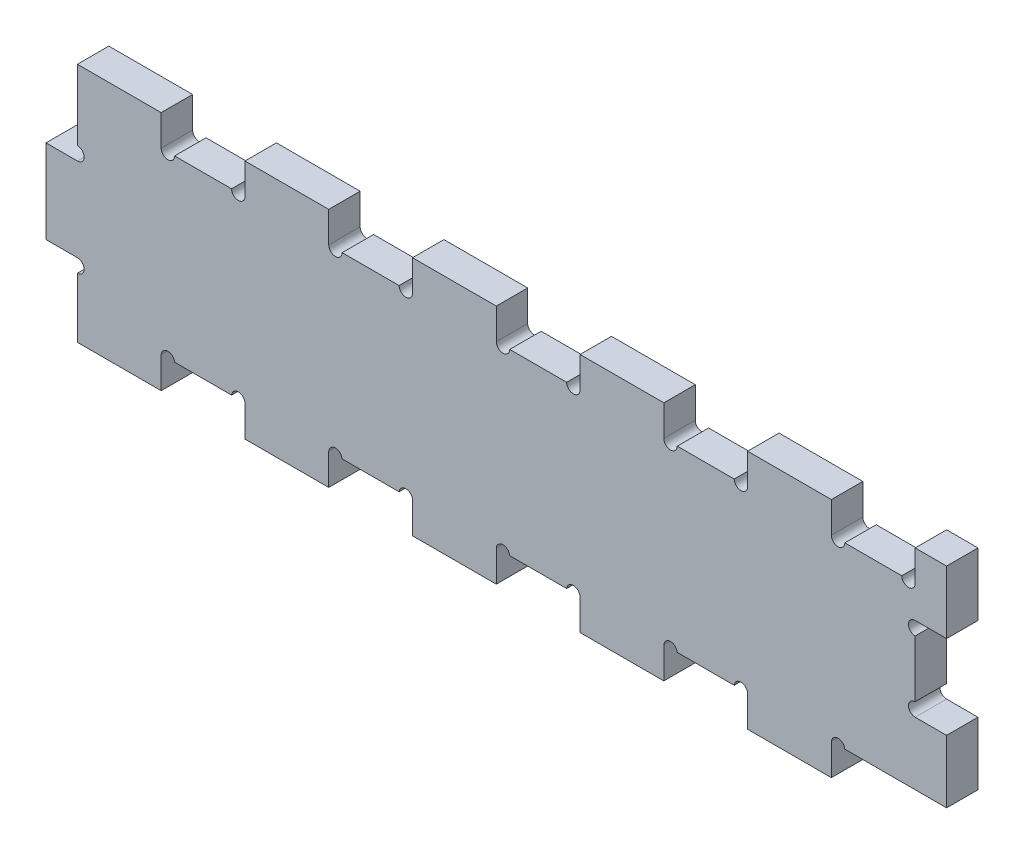
from build123d import *

# Parameters (mm, degrees)
SALIENTE_EXTRUIR2_DEPTH = 10
SALIENTE_EXTRUIR3_DEPTH = 5
CROQUIS4_W              = 15
CROQUIS4_H              = 40
CORTAR_EXTRUIR1_DEPTH   = 15
CROQUIS5_W              = 15
CROQUIS5_H              = 40
SALIENTE_EXTRUIR4_DEPTH = 15
SALIENTE_EXTRUIR5_DEPTH = 15
CROQUIS7_R              = 3.2
CORTAR_EXTRUIR2_DEPTH   = 15
CROQUIS8_W              = 15
CROQUIS8_H              = 30
SALIENTE_EXTRUIR6_DEPTH = 15
CROQUIS9_W              = 15
CROQUIS9_H              = 40
CORTAR_EXTRUIR3_DEPTH   = 15
SALIENTE_EXTRUIR8_DEPTH = 15
CROQUIS12_R             = 3.2
CORTAR_EXTRUIR4_DEPTH   = 15


with BuildPart() as part:
    # Croquis1 → Saliente-Extruir2 (new body)
    with BuildSketch(Plane.XY):
        with BuildLine():
            Line((-200, -42.5), (-200, -57.5))
            Line((-200, -57.5), (-160, -57.5))
            Line((-160, -57.5), (-160, -49.312229152))
            Line((-160, -49.312229152), (-160, -42.790697674))
            Line((-160, -42.790697674), (-160, -42.5))
            Line((-160, -42.5), (-159.986768718, -42.5))
            ThreePointArc((-159.986768718, -42.5), (-156.8, -39.590697674), (-153.613231282, -42.5))
            Line((-153.613231282, -42.5), (-126.386768718, -42.5))
            ThreePointArc((-126.386768718, -42.5), (-123.2, -39.590697674), (-120.013231282, -42.5))
            Line((-120.013231282, -42.5), (-120, -42.5))
            Line((-120, -42.5), (-120, -42.790697674))
            Line((-120, -42.790697674), (-120, -57.5))
            Line((-120, -57.5), (-80, -57.5))
            Line((-80, -57.5), (-80, -42.790697674))
            Line((-80, -42.790697674), (-80, -42.5))
            Line((-80, -42.5), (-79.986768718, -42.5))
            ThreePointArc((-79.986768718, -42.5), (-76.8, -39.590697674), (-73.613231282, -42.5))
            Line((-73.613231282, -42.5), (-46.386768718, -42.5))
            ThreePointArc((-46.386768718, -42.5), (-43.2, -39.590697674), (-40.013231282, -42.5))
            Line((-40.013231282, -42.5), (-40, -42.5))
            Line((-40, -42.5), (-40, -42.790697674))
            Line((-40, -42.790697674), (-40, -57.5))
            Line((-40, -57.5), (0, -57.5))
            Line((0, -57.5), (0, -42.790697674))
            Line((0, -42.790697674), (0, -42.5))
            Line((0, -42.5), (0.013231282, -42.5))
            ThreePointArc((0.013231282, -42.5), (3.2, -39.590697674), (6.386768718, -42.5))
            Line((6.386768718, -42.5), (33.613231282, -42.5))
            ThreePointArc((33.613231282, -42.5), (36.8, -39.590697674), (39.986768718, -42.5))
            Line((39.986768718, -42.5), (40, -42.5))
            Line((40, -42.5), (40, -42.790697674))
            Line((40, -42.790697674), (40, -57.5))
            Line((40, -57.5), (80, -57.5))
            Line((80, -57.5), (80, -42.790697674))
            Line((80, -42.790697674), (80, -42.5))
            Line((80, -42.5), (80.013231282, -42.5))
            ThreePointArc((80.013231282, -42.5), (83.2, -39.590697674), (86.386768718, -42.5))
            Line((86.386768718, -42.5), (113.613231282, -42.5))
            ThreePointArc((113.613231282, -42.5), (116.8, -39.590697674), (119.986768718, -42.5))
            Line((119.986768718, -42.5), (120, -42.5))
            Line((120, -42.5), (120, -42.790697674))
            Line((120, -42.790697674), (120, -57.5))
            Line((120, -57.5), (160, -57.5))
            Line((160, -57.5), (160, -42.790697674))
            Line((160, -42.790697674), (160, -42.5))
            Line((160, -42.5), (160.013231282, -42.5))
            ThreePointArc((160.013231282, -42.5), (163.2, -39.590697674), (166.386768718, -42.5))
            Line((166.386768718, -42.5), (200, -42.5))
            Line((200, -42.5), (215, -42.5))
            Line((215, -42.5), (215, -12.209302326))
            Line((215, -12.209302326), (200, -12.209302326))
            ThreePointArc((200, -12.209302326), (196.8, -9.009302326), (200, -5.809302326))
            Line((200, -5.809302326), (200, 7.790697674))
            Line((200, 7.790697674), (200, 21.390697674))
            ThreePointArc((200, 21.390697674), (196.8, 24.590697674), (200, 27.790697674))
            Line((200, 27.790697674), (215, 27.790697674))
            Line((215, 27.790697674), (215, 57.5))
            Line((215, 57.5), (200, 57.5))
            Line((200, 57.5), (200, 42.790697674))
            ThreePointArc((200, 42.790697674), (196.8, 39.590697674), (193.6, 42.790697674))
            Line((193.6, 42.790697674), (166.4, 42.790697674))
            ThreePointArc((166.4, 42.790697674), (163.2, 39.590697674), (160, 42.790697674))
            Line((160, 42.790697674), (160, 57.5))
            Line((160, 57.5), (140, 57.5))
            Line((140, 57.5), (120, 57.5))
            Line((120, 57.5), (120, 42.790697674))
            ThreePointArc((120, 42.790697674), (116.8, 39.590697674), (113.6, 42.790697674))
            Line((113.6, 42.790697674), (86.4, 42.790697674))
            ThreePointArc((86.4, 42.790697674), (83.2, 39.590697674), (80, 42.790697674))
            Line((80, 42.790697674), (80, 57.5))
            Line((80, 57.5), (40, 57.5))
            Line((40, 57.5), (40, 42.790697674))
            ThreePointArc((40, 42.790697674), (36.8, 39.590697674), (33.6, 42.790697674))
            Line((33.6, 42.790697674), (6.4, 42.790697674))
            ThreePointArc((6.4, 42.790697674), (3.2, 39.590697674), (0, 42.790697674))
            Line((0, 42.790697674), (0, 57.5))
            Line((0, 57.5), (-20, 57.5))
            Line((-20, 57.5), (-40, 57.5))
            Line((-40, 57.5), (-40, 42.790697674))
            ThreePointArc((-40, 42.790697674), (-43.2, 39.590697674), (-46.4, 42.790697674))
            Line((-46.4, 42.790697674), (-73.6, 42.790697674))
            ThreePointArc((-73.6, 42.790697674), (-76.8, 39.590697674), (-80, 42.790697674))
            Line((-80, 42.790697674), (-80, 57.5))
            Line((-80, 57.5), (-100, 57.5))
            Line((-100, 57.5), (-120, 57.5))
            Line((-120, 57.5), (-120, 42.790697674))
            ThreePointArc((-120, 42.790697674), (-123.2, 39.590697674), (-126.4, 42.790697674))
            Line((-126.4, 42.790697674), (-140, 42.790697674))
            Line((-140, 42.790697674), (-153.6, 42.790697674))
            ThreePointArc((-153.6, 42.790697674), (-156.8, 39.590697674), (-160, 42.790697674))
            Line((-160, 42.790697674), (-160, 57.5))
            Line((-160, 57.5), (-200, 57.5))
            Line((-200, 57.5), (-200, 42.790697674))
            Line((-200, 42.790697674), (-200, 26.4))
            ThreePointArc((-200, 26.4), (-196.8, 23.2), (-200, 20))
            Line((-200, 20), (-215, 20))
            Line((-215, 20), (-215, 0))
            Line((-215, 0), (-215, -20))
            Line((-215, -20), (-200, -20))
            ThreePointArc((-200, -20), (-196.8, -23.2), (-200, -26.4))
            Line((-200, -26.4), (-200, -42.5))
        make_face()
    extrude(amount=SALIENTE_EXTRUIR2_DEPTH)

    # Croquis3 → Saliente-Extruir3 (add)
    with BuildSketch(Plane.XY.offset(10)):
        with BuildLine():
            Line((119.986768718, -42.5), (120, -42.5))
            Line((120, -42.5), (120, -57.5))
            Line((120, -57.5), (160, -57.5))
            Line((160, -57.5), (160, -42.5))
            Line((160, -42.5), (160.013231282, -42.5))
            ThreePointArc((160.013231282, -42.5), (163.2, -39.590697674), (166.386768718, -42.5))
            Line((166.386768718, -42.5), (215, -42.5))
            Line((215, -42.5), (215, -12.209302326))
            Line((215, -12.209302326), (200, -12.209302326))
            ThreePointArc((200, -12.209302326), (196.8, -9.009302326), (200, -5.809302326))
            Line((200, -5.809302326), (200, 21.390697674))
            ThreePointArc((200, 21.390697674), (196.8, 24.590697674), (200, 27.790697674))
            Line((200, 27.790697674), (215, 27.790697674))
            Line((215, 27.790697674), (215, 57.5))
            Line((215, 57.5), (200, 57.5))
            Line((200, 57.5), (200, 42.790697674))
            ThreePointArc((200, 42.790697674), (196.8, 39.590697674), (193.6, 42.790697674))
            Line((193.6, 42.790697674), (166.4, 42.790697674))
            ThreePointArc((166.4, 42.790697674), (163.2, 39.590697674), (160, 42.790697674))
            Line((160, 42.790697674), (160, 57.5))
            Line((160, 57.5), (120, 57.5))
            Line((120, 57.5), (120, 42.790697674))
            ThreePointArc((120, 42.790697674), (116.8, 39.590697674), (113.6, 42.790697674))
            Line((113.6, 42.790697674), (86.4, 42.790697674))
            ThreePointArc((86.4, 42.790697674), (83.2, 39.590697674), (80, 42.790697674))
            Line((80, 42.790697674), (80, 57.5))
            Line((80, 57.5), (40, 57.5))
            Line((40, 57.5), (40, 42.790697674))
            ThreePointArc((40, 42.790697674), (36.8, 39.590697674), (33.6, 42.790697674))
            Line((33.6, 42.790697674), (6.4, 42.790697674))
            ThreePointArc((6.4, 42.790697674), (3.2, 39.590697674), (0, 42.790697674))
            Line((0, 42.790697674), (0, 57.5))
            Line((0, 57.5), (-40, 57.5))
            Line((-40, 57.5), (-40, 42.790697674))
            ThreePointArc((-40, 42.790697674), (-43.2, 39.590697674), (-46.4, 42.790697674))
            Line((-46.4, 42.790697674), (-73.6, 42.790697674))
            ThreePointArc((-73.6, 42.790697674), (-76.8, 39.590697674), (-80, 42.790697674))
            Line((-80, 42.790697674), (-80, 57.5))
            Line((-80, 57.5), (-120, 57.5))
            Line((-120, 57.5), (-120, 42.790697674))
            ThreePointArc((-120, 42.790697674), (-123.2, 39.590697674), (-126.4, 42.790697674))
            Line((-126.4, 42.790697674), (-153.6, 42.790697674))
            ThreePointArc((-153.6, 42.790697674), (-156.8, 39.590697674), (-160, 42.790697674))
            Line((-160, 42.790697674), (-160, 57.5))
            Line((-160, 57.5), (-200, 57.5))
            Line((-200, 57.5), (-200, 26.4))
            ThreePointArc((-200, 26.4), (-196.8, 23.2), (-200, 20))
            Line((-200, 20), (-215, 20))
            Line((-215, 20), (-215, -20))
            Line((-215, -20), (-200, -20))
            ThreePointArc((-200, -20), (-196.8, -23.2), (-200, -26.4))
            Line((-200, -26.4), (-200, -57.5))
            Line((-200, -57.5), (-160, -57.5))
            Line((-160, -57.5), (-160, -42.5))
            Line((-160, -42.5), (-159.986768718, -42.5))
            ThreePointArc((-159.986768718, -42.5), (-156.8, -39.590697674), (-153.613231282, -42.5))
            Line((-153.613231282, -42.5), (-126.386768718, -42.5))
            ThreePointArc((-126.386768718, -42.5), (-123.2, -39.590697674), (-120.013231282, -42.5))
            Line((-120.013231282, -42.5), (-120, -42.5))
            Line((-120, -42.5), (-120, -57.5))
            Line((-120, -57.5), (-80, -57.5))
            Line((-80, -57.5), (-80, -42.5))
            Line((-80, -42.5), (-79.986768718, -42.5))
            ThreePointArc((-79.986768718, -42.5), (-76.8, -39.590697674), (-73.613231282, -42.5))
            Line((-73.613231282, -42.5), (-46.386768718, -42.5))
            ThreePointArc((-46.386768718, -42.5), (-43.2, -39.590697674), (-40.013231282, -42.5))
            Line((-40.013231282, -42.5), (-40, -42.5))
            Line((-40, -42.5), (-40, -57.5))
            Line((-40, -57.5), (0, -57.5))
            Line((0, -57.5), (0, -42.5))
            Line((0, -42.5), (0.013231282, -42.5))
            ThreePointArc((0.013231282, -42.5), (3.2, -39.590697674), (6.386768718, -42.5))
            Line((6.386768718, -42.5), (33.613231282, -42.5))
            ThreePointArc((33.613231282, -42.5), (36.8, -39.590697674), (39.986768718, -42.5))
            Line((39.986768718, -42.5), (40, -42.5))
            Line((40, -42.5), (40, -57.5))
            Line((40, -57.5), (80, -57.5))
            Line((80, -57.5), (80, -42.5))
            Line((80, -42.5), (80.013231282, -42.5))
            ThreePointArc((80.013231282, -42.5), (83.2, -39.590697674), (86.386768718, -42.5))
            Line((86.386768718, -42.5), (113.613231282, -42.5))
            ThreePointArc((113.613231282, -42.5), (116.8, -39.590697674), (119.986768718, -42.5))
        make_face()
    extrude(amount=SALIENTE_EXTRUIR3_DEPTH)

    # Croquis4 → Cortar-Extruir1 (cut)
    with BuildSketch(Plane.XY.offset(15)):
        with Locations((-207.5, 37.5)):
            Rectangle(CROQUIS4_W, CROQUIS4_H)
    extrude(amount=-CORTAR_EXTRUIR1_DEPTH, mode=Mode.SUBTRACT)

    # Croquis5 → Saliente-Extruir4 (add)
    with BuildSketch(Plane.XY.offset(15)):
        with Locations((-207.5, -2.5)):
            Rectangle(CROQUIS5_W, CROQUIS5_H)
    extrude(amount=-SALIENTE_EXTRUIR4_DEPTH)

    # Croquis6 → Saliente-Extruir5 (add)
    with BuildSketch(Plane.XY.offset(15)):
        with BuildLine():
            Line((-200, -22.5), (-200, -20))
            ThreePointArc((-200, -20), (-196.8, -23.2), (-200, -26.4))
            Line((-200, -26.4), (-200, -22.5))
        make_face()
        with BuildLine():
            Line((-200, 20), (-200, 26.4))
            ThreePointArc((-200, 26.4), (-196.8, 23.2), (-200, 20))
        make_face()
    extrude(amount=-SALIENTE_EXTRUIR5_DEPTH)

    # Croquis7 → Cortar-Extruir2 (cut)
    with BuildSketch(Plane.XY.offset(15)):
        with Locations((-200, 20.7)):
            Circle(CROQUIS7_R)
        with Locations((-200, -25.7)):
            Circle(CROQUIS7_R)
    extrude(amount=-CORTAR_EXTRUIR2_DEPTH, mode=Mode.SUBTRACT)

    # Croquis8 → Saliente-Extruir6 (add)
    with BuildSketch(Plane.XY.offset(15)):
        with Locations((207.5, 42.5)):
            Rectangle(CROQUIS8_W, CROQUIS8_H)
    extrude(amount=-SALIENTE_EXTRUIR6_DEPTH)

    # Croquis9 → Cortar-Extruir3 (cut)
    with BuildSketch(Plane.XY.offset(15)):
        with Locations((207.5, 7.5)):
            Rectangle(CROQUIS9_W, CROQUIS9_H)
    extrude(amount=-CORTAR_EXTRUIR3_DEPTH, mode=Mode.SUBTRACT)

    # Croquis10 → Saliente-Extruir8 (add)
    with BuildSketch(Plane.XY.offset(15)):
        with BuildLine():
            Line((200, -5.809302326), (200, -12.209302326))
            ThreePointArc((200, -12.209302326), (196.8, -9.009302326), (200, -5.809302326))
        make_face()
        with BuildLine():
            Line((200, 27.5), (200, 21.390697674))
            ThreePointArc((200, 21.390697674), (196.8, 24.590697674), (200, 27.790697674))
            Line((200, 27.790697674), (200, 27.5))
        make_face()
    extrude(amount=-SALIENTE_EXTRUIR8_DEPTH)

    # Croquis12 → Cortar-Extruir4 (cut)
    with BuildSketch(Plane.XY.offset(15)):
        with Locations((200, 24.3)):
            Circle(CROQUIS12_R)
        with Locations((200, -9.3)):
            Circle(CROQUIS12_R)
    extrude(amount=-CORTAR_EXTRUIR4_DEPTH, mode=Mode.SUBTRACT)


solid = part.part
